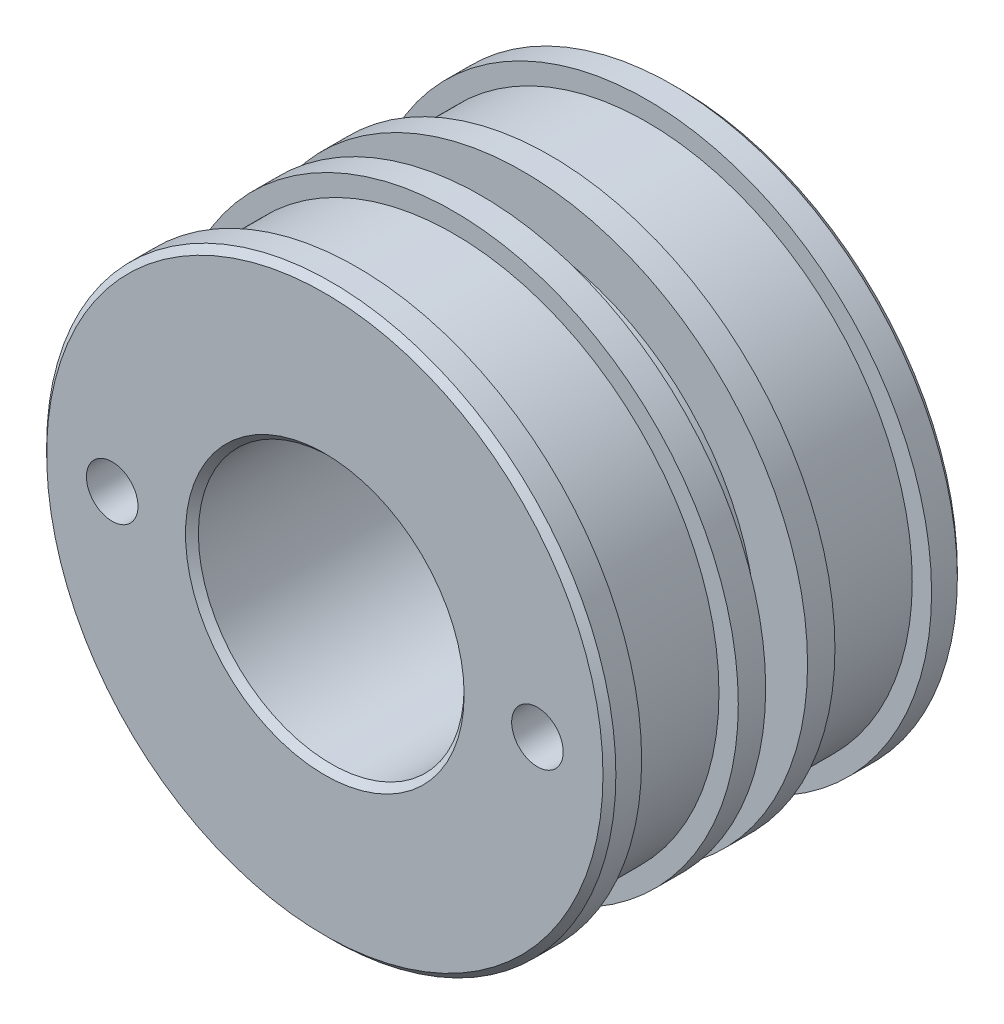
from build123d import *

# Parameters (mm, degrees)
SKETCH1_R           = 44.175
SKETCH1_R_2         = 20.625
BOSS_EXTRUDE1_DEPTH = 55
SKETCH2_W           = 15
SKETCH2_H           = 3
SKETCH2_W_2         = 6.5
SKETCH2_H_2         = 8
CHAMFER1_SIZE       = 1
SKETCH3_R           = 24.5
CUT_EXTRUDE1_DEPTH  = 15
CHAMFER2_SIZE       = 1
SKETCH4_R           = 4
CUT_EXTRUDE2_DEPTH  = 9


with BuildPart() as part:
    # Sketch1 → Boss-Extrude1 (new body)
    with BuildSketch(Plane.XY):
        Circle(SKETCH1_R)
        Circle(SKETCH1_R_2, mode=Mode.SUBTRACT)
    extrude(amount=-BOSS_EXTRUDE1_DEPTH)

    # Sketch2 → Cut-Revolve1 (revolve, cut)
    with BuildSketch(Plane(origin=(0, 0, 0), x_dir=(0, 0, -1), z_dir=(1, 0, 0))):
        with Locations((12.5, 42.675)):
            Rectangle(SKETCH2_W, SKETCH2_H)
        with Locations((42.5, 42.675)):
            Rectangle(SKETCH2_W, SKETCH2_H)
        with Locations((27.5, 40.175)):
            Rectangle(SKETCH2_W_2, SKETCH2_H_2)
    revolve(axis=Axis((0, 0, 0), (0, 0, -1)), mode=Mode.SUBTRACT)

    # Chamfer1
    chamfer1_edges = [part.edges().sort_by_distance(p)[0] for p in [
        (-44.175, 0, 0),
        (-44.175, 0, -55),
        (-20.625, 0, -55),
        (-20.625, 0, 0),
    ]]
    chamfer(chamfer1_edges, length=CHAMFER1_SIZE)

    # Sketch3 → Cut-Extrude1 (cut)
    with BuildSketch(Plane(origin=(0, 0, -55), x_dir=(-1, 0, 0), z_dir=(0, 0, -1))):
        Circle(SKETCH3_R)
    extrude(amount=-CUT_EXTRUDE1_DEPTH, mode=Mode.SUBTRACT)

    # Chamfer2
    chamfer2_edges = [part.edges().sort_by_distance(p)[0] for p in [
        (24.5, 0, -55),
    ]]
    chamfer(chamfer2_edges, length=CHAMFER2_SIZE)

    # Sketch4 → Cut-Extrude2 (cut)
    with BuildSketch(Plane.XY):
        with Locations((-33, 0)):
            Circle(SKETCH4_R)
        with Locations((33, 0)):
            Circle(SKETCH4_R)
    extrude(amount=-CUT_EXTRUDE2_DEPTH, mode=Mode.SUBTRACT)


solid = part.part
